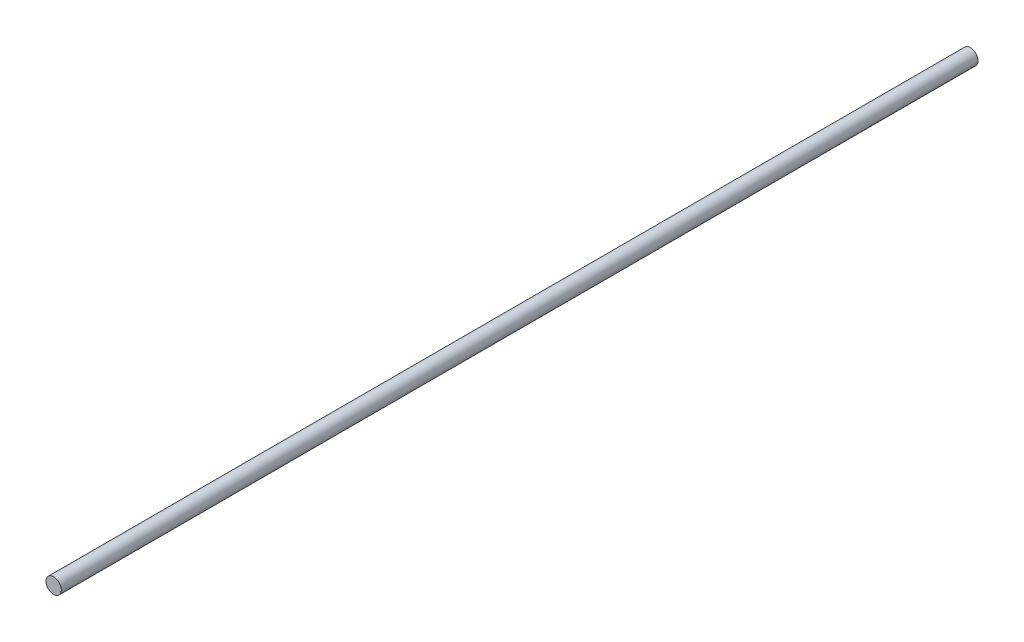
from build123d import *

# Parameters (mm, degrees)
ESQUISSE1_R        = 2.5
BOSS_EXTRU_1_DEPTH = 298.65


with BuildPart() as part:
    # Esquisse1 → Boss.-Extru.1 (new body)
    with BuildSketch(Plane.XY):
        Circle(ESQUISSE1_R)
    extrude(amount=BOSS_EXTRU_1_DEPTH)


solid = part.part
